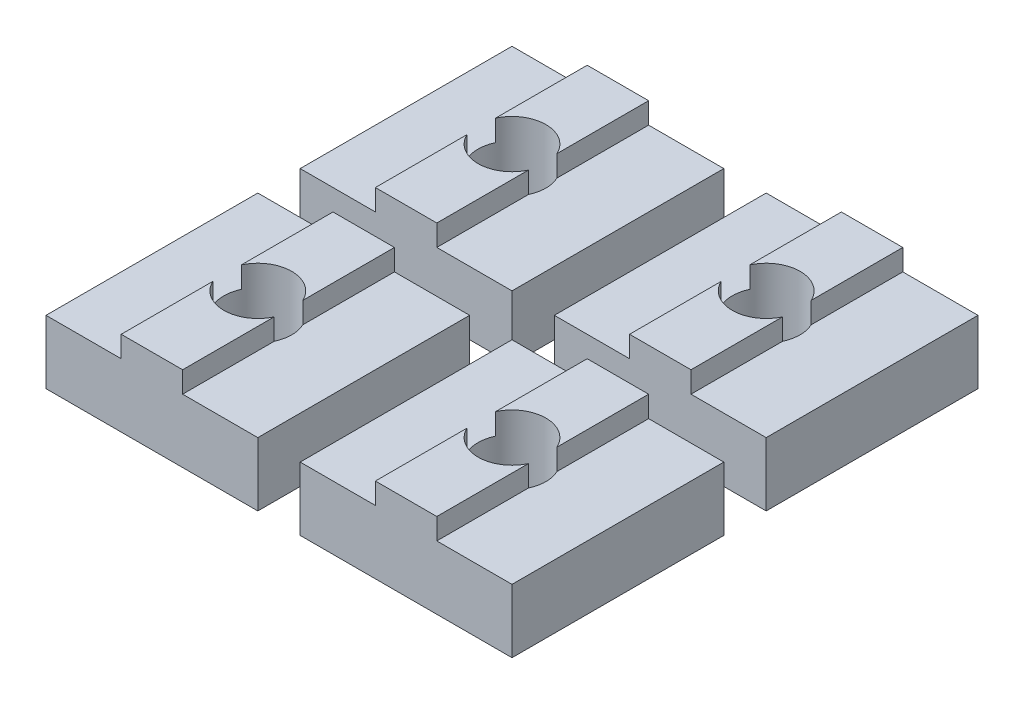
from build123d import *

# Parameters (mm, degrees)
MAIN_DEPTH                 = 10
ESQUISSE2_R                = 1.6
TOPHOLE_DEPTH              = 12.874342087
R_P_TITION_LIN_AIRE1_COUNT = 2
R_P_TITION_LIN_AIRE1_PITCH = 12
LPATTERN1_COUNT            = 2
LPATTERN1_PITCH            = 12


with BuildPart() as part:
    # Esquisse1 → Main (new body)
    with BuildSketch(Plane.XY):
        Polygon((-5, 0), (-5, 3), (-1.45, 3), (-1.45, 4), (1.45, 4), (1.45, 3), (5, 3), (5, 0), align=None)
    extrude(amount=MAIN_DEPTH)

    # Esquisse2 → TopHole (cut, through all)
    with BuildSketch(Plane(origin=(0, 4, 0), x_dir=(1, 0, 0), z_dir=(0, 1, 0))):
        with Locations((0, -5)):
            Circle(ESQUISSE2_R)
    extrude(amount=-TOPHOLE_DEPTH, mode=Mode.SUBTRACT)


with BuildPart() as r_p_tition_lin_aire1_1:
    # Répétition linéaire1: pattern copy
    add(part.part.moved(Location(Vector(-1, 0, 0) * (1 * R_P_TITION_LIN_AIRE1_PITCH))))


with BuildPart() as lpattern1_1:
    # LPattern1: pattern copy
    add(r_p_tition_lin_aire1_1.part.moved(Location(Vector(0, 0, 1) * (1 * LPATTERN1_PITCH))))


with BuildPart() as lpattern1_2:
    # LPattern1: pattern copy
    add(part.part.moved(Location(Vector(0, 0, 1) * (1 * LPATTERN1_PITCH))))


solid = Compound([part.part, r_p_tition_lin_aire1_1.part, lpattern1_1.part, lpattern1_2.part])
